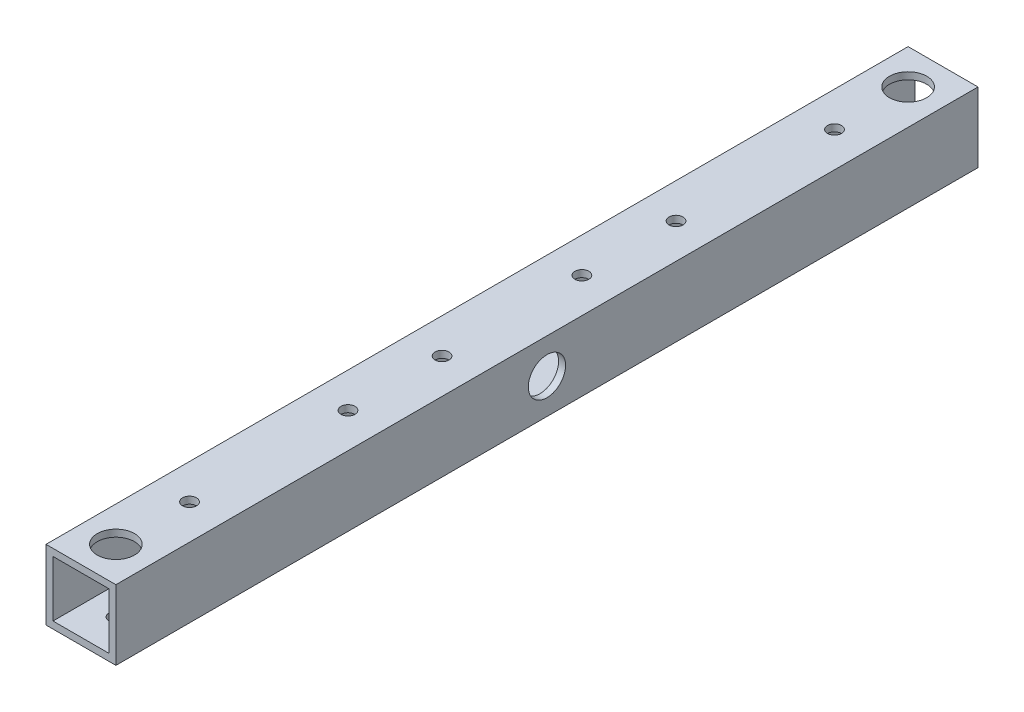
from build123d import *

# Parameters (mm, degrees)
SKETCH_1_W           = 15
SKETCH_1_H           = 15
SKETCH_1_W_2         = 12
SKETCH_1_H_2         = 12
EXTRUDE_2_DEPTH      = 185
SKETCH_2_R           = 4
CUT_EXTRUDE_1_DEPTH  = 10
SKETCH_3_R           = 1.5
CUT_EXTRUDE_2_DEPTH  = 10
SKETCH_4_R           = 4
CUT_EXTRUDE_3_DEPTH  = 10
SKETCH_5_R           = 1.5
CUT_EXTRUDE_4_DEPTH  = 10
SKETCH_6_R           = 1.5
CUT_EXTRUDE_5_DEPTH  = 10
SKETCH_7_R           = 4
CUT_EXTRUDE_6_DEPTH  = 10
SKETCH_8_R           = 1.5
CUT_EXTRUDE_7_DEPTH  = 10
SKETCH_9_R           = 1.5
CUT_EXTRUDE_8_DEPTH  = 10
SKETCH_10_R          = 4
CUT_EXTRUDE_9_DEPTH  = 10
SKETCH_11_R          = 4
CUT_EXTRUDE_10_DEPTH = 10
SKETCH_12_R          = 1.5
CUT_EXTRUDE_11_DEPTH = 10
SKETCH_14_R          = 1.5
CUT_EXTRUDE_12_DEPTH = 10
SKETCH_15_R          = 4
CUT_EXTRUDE_13_DEPTH = 10
SKETCH_16_R          = 4
CUT_EXTRUDE_14_DEPTH = 10
SKETCH_18_R          = 1.5
CUT_EXTRUDE_15_DEPTH = 10
SKETCH_19_R          = 1.5
CUT_EXTRUDE_16_DEPTH = 10
SKETCH_20_R          = 4
CUT_EXTRUDE_17_DEPTH = 10
SKETCH_21_R          = 4
CUT_EXTRUDE_18_DEPTH = 10


with BuildPart() as part:
    # ｽｹｯﾁ1 → ﾎﾞｽ - 押し出し2 (new body)
    with BuildSketch(Plane.XY):
        with Locations((0.489915859, 0.232626086)):
            Rectangle(SKETCH_1_W, SKETCH_1_H)
        with Locations((0.489915859, 0.232626086)):
            Rectangle(SKETCH_1_W_2, SKETCH_1_H_2, mode=Mode.SUBTRACT)
    extrude(amount=EXTRUDE_2_DEPTH)

    # ｽｹｯﾁ2 → ｶｯﾄ - 押し出し1 (cut)
    with BuildSketch(Plane(origin=(0, 7.732626086, 0), x_dir=(1, 0, 0), z_dir=(0, 1, 0))):
        with Locations((0.489915859, -177.5)):
            Circle(SKETCH_2_R)
    extrude(amount=-CUT_EXTRUDE_1_DEPTH, mode=Mode.SUBTRACT)

    # ｽｹｯﾁ3 → ｶｯﾄ - 押し出し2 (cut)
    with BuildSketch(Plane.XZ.offset(7.267373914)):
        with Locations((0.489915859, 177.5)):
            Circle(SKETCH_3_R)
    extrude(amount=-CUT_EXTRUDE_2_DEPTH, mode=Mode.SUBTRACT)

    # ｽｹｯﾁ4 → ｶｯﾄ - 押し出し3 (cut)
    with BuildSketch(Plane(origin=(0, 7.732626086, 0), x_dir=(1, 0, 0), z_dir=(0, 1, 0))):
        with Locations((0.489915859, -7.5)):
            Circle(SKETCH_4_R)
    extrude(amount=-CUT_EXTRUDE_3_DEPTH, mode=Mode.SUBTRACT)

    # ｽｹｯﾁ5 → ｶｯﾄ - 押し出し4 (cut)
    with BuildSketch(Plane.XZ.offset(7.267373914)):
        with Locations((0.489915859, 7.5)):
            Circle(SKETCH_5_R)
    extrude(amount=-CUT_EXTRUDE_4_DEPTH, mode=Mode.SUBTRACT)

    # ｽｹｯﾁ6 → ｶｯﾄ - 押し出し5 (cut)
    with BuildSketch(Plane.ZY.offset(7.010084141)):
        with Locations((92.5, 0.232626086)):
            Circle(SKETCH_6_R)
    extrude(amount=-CUT_EXTRUDE_5_DEPTH, mode=Mode.SUBTRACT)

    # ｽｹｯﾁ7 → ｶｯﾄ - 押し出し6 (cut)
    with BuildSketch(Plane(origin=(7.989915859, 0, 0), x_dir=(0, 0, -1), z_dir=(1, 0, 0))):
        with Locations((-92.5, 0.232626086)):
            Circle(SKETCH_7_R)
    extrude(amount=-CUT_EXTRUDE_6_DEPTH, mode=Mode.SUBTRACT)

    # ｽｹｯﾁ8 → ｶｯﾄ - 押し出し7 (cut)
    with BuildSketch(Plane(origin=(0, 7.732626086, 0), x_dir=(1, 0, 0), z_dir=(0, 1, 0))):
        with Locations((0.489915859, -77.5)):
            Circle(SKETCH_8_R)
    extrude(amount=-CUT_EXTRUDE_7_DEPTH, mode=Mode.SUBTRACT)

    # ｽｹｯﾁ9 → ｶｯﾄ - 押し出し8 (cut)
    with BuildSketch(Plane(origin=(0, 7.732626086, 0), x_dir=(1, 0, 0), z_dir=(0, 1, 0))):
        with Locations((0.489915859, -107.5)):
            Circle(SKETCH_9_R)
    extrude(amount=-CUT_EXTRUDE_8_DEPTH, mode=Mode.SUBTRACT)

    # ｽｹｯﾁ10 → ｶｯﾄ - 押し出し9 (cut)
    with BuildSketch(Plane.XZ.offset(7.267373914)):
        with Locations((0.489915859, 77.5)):
            Circle(SKETCH_10_R)
    extrude(amount=-CUT_EXTRUDE_9_DEPTH, mode=Mode.SUBTRACT)

    # ｽｹｯﾁ11 → ｶｯﾄ - 押し出し10 (cut)
    with BuildSketch(Plane.XZ.offset(7.267373914)):
        with Locations((0.489915859, 107.5)):
            Circle(SKETCH_11_R)
    extrude(amount=-CUT_EXTRUDE_10_DEPTH, mode=Mode.SUBTRACT)

    # ｽｹｯﾁ12 → ｶｯﾄ - 押し出し11 (cut)
    with BuildSketch(Plane(origin=(0, 7.732626086, 0), x_dir=(1, 0, 0), z_dir=(0, 1, 0))):
        with Locations((0.489915859, -23.3)):
            Circle(SKETCH_12_R)
    extrude(amount=-CUT_EXTRUDE_11_DEPTH, mode=Mode.SUBTRACT)

    # ｽｹｯﾁ14 → ｶｯﾄ - 押し出し12 (cut)
    with BuildSketch(Plane(origin=(0, 7.732626086, 0), x_dir=(1, 0, 0), z_dir=(0, 1, 0))):
        with Locations((0.489915859, -57.3)):
            Circle(SKETCH_14_R)
    extrude(amount=-CUT_EXTRUDE_12_DEPTH, mode=Mode.SUBTRACT)

    # ｽｹｯﾁ15 → ｶｯﾄ - 押し出し13 (cut)
    with BuildSketch(Plane.XZ.offset(7.267373914)):
        with Locations((0.489915859, 23.3)):
            Circle(SKETCH_15_R)
    extrude(amount=-CUT_EXTRUDE_13_DEPTH, mode=Mode.SUBTRACT)

    # ｽｹｯﾁ16 → ｶｯﾄ - 押し出し14 (cut)
    with BuildSketch(Plane.XZ.offset(7.267373914)):
        with Locations((0.489915859, 57.3)):
            Circle(SKETCH_16_R)
    extrude(amount=-CUT_EXTRUDE_14_DEPTH, mode=Mode.SUBTRACT)

    # ｽｹｯﾁ18 → ｶｯﾄ - 押し出し15 (cut)
    with BuildSketch(Plane(origin=(0, 7.732626086, 0), x_dir=(1, 0, 0), z_dir=(0, 1, 0))):
        with Locations((0.489915859, -161.7)):
            Circle(SKETCH_18_R)
    extrude(amount=-CUT_EXTRUDE_15_DEPTH, mode=Mode.SUBTRACT)

    # ｽｹｯﾁ19 → ｶｯﾄ - 押し出し16 (cut)
    with BuildSketch(Plane(origin=(0, 7.732626086, 0), x_dir=(1, 0, 0), z_dir=(0, 1, 0))):
        with Locations((0.489915859, -127.7)):
            Circle(SKETCH_19_R)
    extrude(amount=-CUT_EXTRUDE_16_DEPTH, mode=Mode.SUBTRACT)

    # ｽｹｯﾁ20 → ｶｯﾄ - 押し出し17 (cut)
    with BuildSketch(Plane.XZ.offset(7.267373914)):
        with Locations((0.489915859, 161.7)):
            Circle(SKETCH_20_R)
    extrude(amount=-CUT_EXTRUDE_17_DEPTH, mode=Mode.SUBTRACT)

    # ｽｹｯﾁ21 → ｶｯﾄ - 押し出し18 (cut)
    with BuildSketch(Plane(origin=(0, -7.267373914, 0), x_dir=(-1, 0, 0), z_dir=(0, -1, 0))):
        with Locations((-0.489915859, -127.7)):
            Circle(SKETCH_21_R)
    extrude(amount=-CUT_EXTRUDE_18_DEPTH, mode=Mode.SUBTRACT)


solid = part.part
